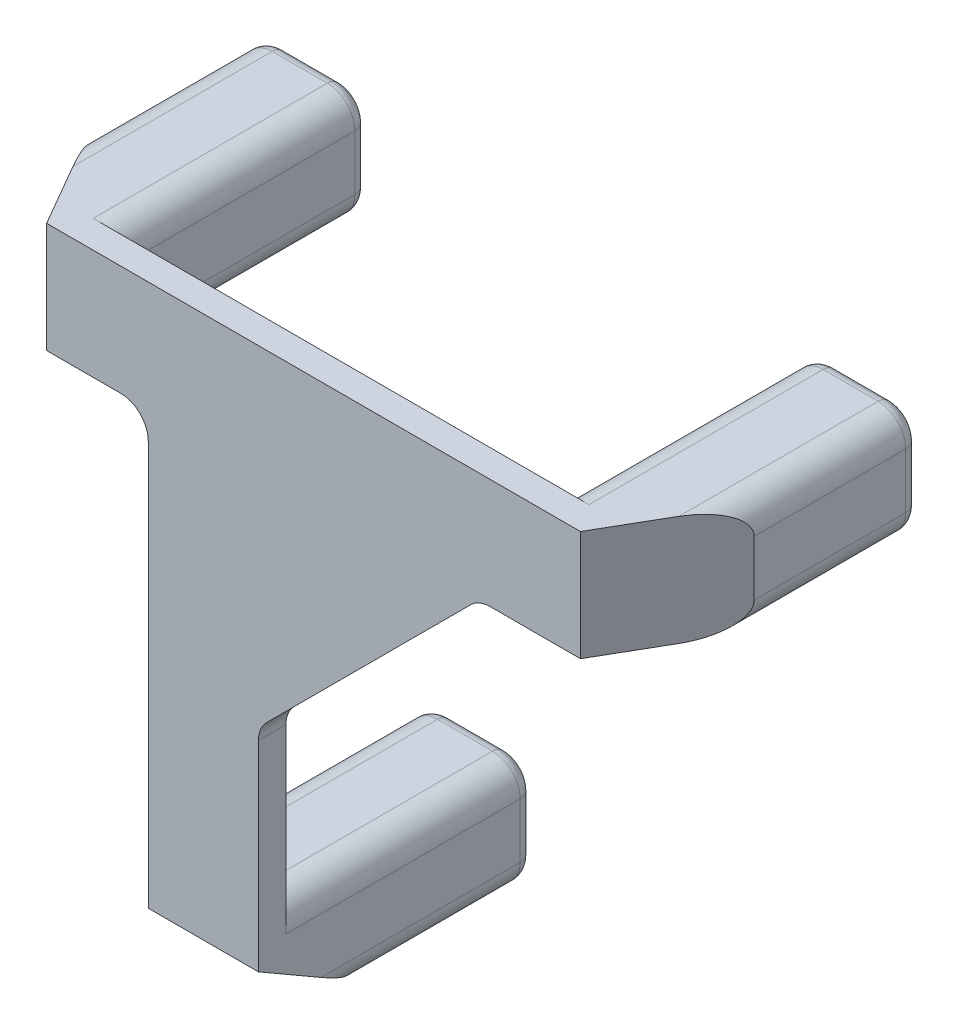
from build123d import *

# Parameters (mm, degrees)
BOSS_EXTRUDE1_DEPTH   = 3.175
SKETCH2_W             = 12.7
SKETCH2_H             = 12.7
BOSS_EXTRUDE2_DEPTH   = 28.575
SKETCH3_R             = 2.5
CUT_EXTRUDE1_DEPTH    = 10
CHAMFER1_SIZE         = 12.7
CHAMFER1_SIZE2        = 7.332348419
CHAMFER1_PART_2_SIZE  = 12.7
CHAMFER1_PART_2_SIZE2 = 7.332348419
CHAMFER1_PART_3_SIZE  = 12.7
CHAMFER1_PART_3_SIZE2 = 7.332348419
FILLET1_R             = 3.175
FILLET2_R             = 3.175
FILLET4_R             = 1.5875


with BuildPart() as part:
    # Sketch1 → Boss-Extrude1 (new body)
    with BuildSketch(Plane.XY):
        Polygon((38.1, 0), (-38.1, 0), (-38.1, -12.7), (-19.05, -12.7), (-19.05, -69.85), (-6.35, -69.85), (-6.35, -38.1), (19.05, -12.7), (38.1, -12.7), align=None)
    extrude(amount=BOSS_EXTRUDE1_DEPTH)

    # Sketch2 → Boss-Extrude2 (add)
    with BuildSketch(Plane(origin=(0, 0, 0), x_dir=(-1, 0, 0), z_dir=(0, 0, -1))):
        with Locations((-31.75, -6.35)):
            Rectangle(SKETCH2_W, SKETCH2_H)
        with Locations((31.75, -6.35)):
            Rectangle(SKETCH2_W, SKETCH2_H)
        with Locations((12.7, -63.5)):
            Rectangle(SKETCH2_W, SKETCH2_H)
    extrude(amount=BOSS_EXTRUDE2_DEPTH)

    # Sketch3 → Cut-Extrude1 (cut)
    with BuildSketch(Plane(origin=(0, 0, -28.575), x_dir=(-1, 0, 0), z_dir=(0, 0, -1))):
        with Locations((-31.75, -6.35)):
            Circle(SKETCH3_R)
        with Locations((31.75, -6.35)):
            Circle(SKETCH3_R)
        with Locations((12.7, -63.5)):
            Circle(SKETCH3_R)
    extrude(amount=-CUT_EXTRUDE1_DEPTH, mode=Mode.SUBTRACT)

    # Chamfer1
    chamfer1_edges = [part.edges().sort_by_distance(p)[0] for p in [
        (38.1, -6.35, 3.175),
    ]]
    chamfer1_side = [part.faces().sort_by_distance(p)[0] for p in [
        (38.1, -6.35, -12.7),
    ]]
    chamfer(chamfer1_edges, length=CHAMFER1_SIZE, length2=CHAMFER1_SIZE2, reference=chamfer1_side[0])

    # Chamfer1 part 2
    chamfer1_part_2_edges = [part.edges().sort_by_distance(p)[0] for p in [
        (-38.1, -6.35, 3.175),
    ]]
    chamfer1_part_2_side = [part.faces().sort_by_distance(p)[0] for p in [
        (-38.1, -6.35, -12.7),
    ]]
    chamfer(chamfer1_part_2_edges, length=CHAMFER1_PART_2_SIZE, length2=CHAMFER1_PART_2_SIZE2, reference=chamfer1_part_2_side[0])

    # Chamfer1 part 3
    chamfer1_part_3_edges = [part.edges().sort_by_distance(p)[0] for p in [
        (-12.7, -69.85, 3.175),
    ]]
    chamfer1_part_3_side = [part.faces().sort_by_distance(p)[0] for p in [
        (-12.7, -69.85, -12.7),
    ]]
    chamfer(chamfer1_part_3_edges, length=CHAMFER1_PART_3_SIZE, length2=CHAMFER1_PART_3_SIZE2, reference=chamfer1_part_3_side[0])

    # Fillet1
    fillet1_edges = [part.edges().sort_by_distance(p)[0] for p in [
        (-6.35, -38.1, 1.5875),
        (-19.05, -12.7, 1.5875),
        (19.05, -12.7, 1.5875),
    ]]
    fillet(fillet1_edges, radius=FILLET1_R)

    # Fillet2
    fillet2_edges = [part.edges().sort_by_distance(p)[0] for p in [
        (25.4, -12.7, -14.2875),
        (25.4, 0, -14.2875),
        (-25.4, 0, -14.2875),
        (-25.4, -12.7, -14.2875),
        (-19.05, -57.15, -14.2875),
        (-6.35, -57.15, -14.2875),
        (38.1, 0, -19.05),
        (-38.1, 0, -19.05),
        (38.1, -12.7, -19.05),
        (-6.35, -69.85, -19.05),
        (-19.05, -69.85, -19.05),
        (-38.1, -12.7, -19.05),
    ]]
    fillet(fillet2_edges, radius=FILLET2_R)

    # Fillet4
    fillet4_edges = [part.edges().sort_by_distance(p)[0] for p in [
        (-12.7, -57.15, -28.575),
        (-19.05, -63.5, -28.575),
        (-6.35, -63.5, -28.575),
        (-12.7, -69.85, -28.575),
        (-7.27993597, -58.07993597, -28.575),
        (-7.27993597, -68.92006403, -28.575),
        (-18.12006403, -68.92006403, -28.575),
        (-18.12006403, -58.07993597, -28.575),
        (38.1, -6.35, -28.575),
        (31.75, -12.7, -28.575),
        (25.4, -6.35, -28.575),
        (31.75, 0, -28.575),
        (26.32993597, -11.77006403, -28.575),
        (26.32993597, -0.92993597, -28.575),
        (37.17006403, -0.92993597, -28.575),
        (37.17006403, -11.77006403, -28.575),
        (-31.75, 0, -28.575),
        (-25.4, -6.35, -28.575),
        (-38.1, -6.35, -28.575),
        (-31.75, -12.7, -28.575),
        (-37.17006403, -11.77006403, -28.575),
        (-37.17006403, -0.92993597, -28.575),
        (-26.32993597, -11.77006403, -28.575),
        (-26.32993597, -0.92993597, -28.575),
    ]]
    fillet(fillet4_edges, radius=FILLET4_R)


solid = part.part
